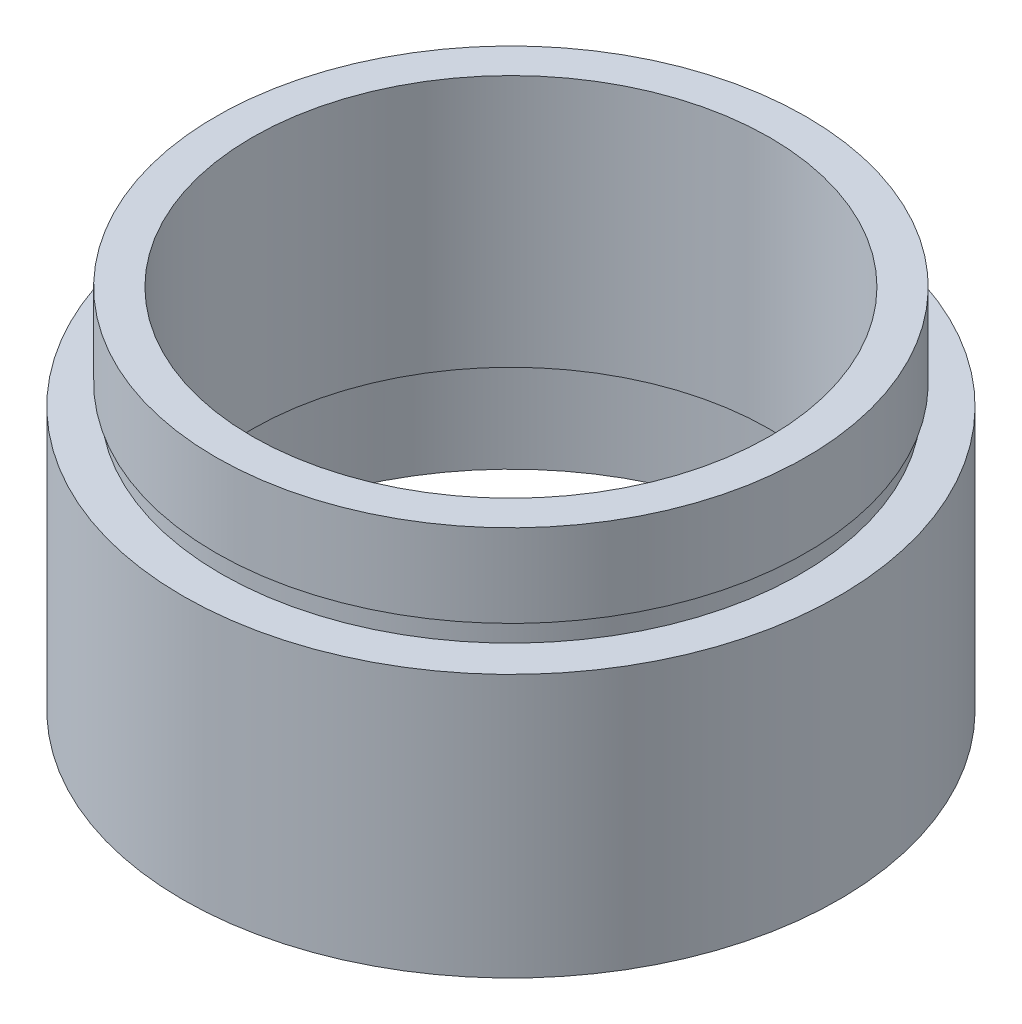
from build123d import *


with BuildPart() as part:
    # 草图1 → 旋转1 (revolve)
    with BuildSketch(Plane.XY, mode=Mode.PRIVATE) as revolve_1_sk:
        Polygon((14.25, 0), (14.25, 4.5), (14.35, 4.5), (14.35, 5.5), (12.5, 5.5), (12.5, 17.7), (14.25, 17.7), (14.25, 13.7), (14, 13.7), (14, 12.7), (15.85, 12.7), (15.85, 0), align=None)
    revolve(revolve_1_sk.sketch.rotate(Axis((0, 161.376166943, 0), (0, -1, 0)), 90), axis=Axis((0, 161.376166943, 0), (0, -1, 0)))  # turned: the seam where the file's is


solid = part.part
